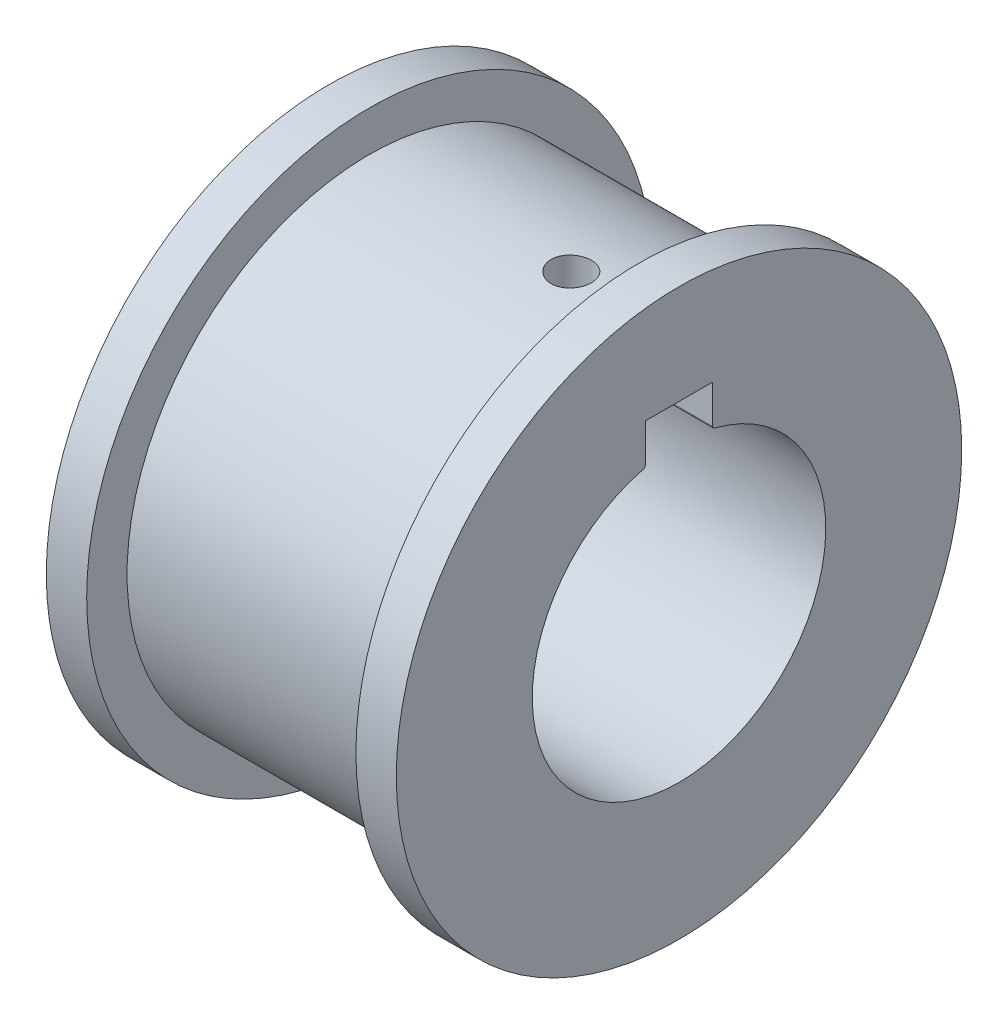
from build123d import *

# Parameters (mm, degrees)
SKETCH1_R               = 18
BOSS_EXTRUDE1_DEPTH     = 20
SKETCH3_R               = 21
BOSS_EXTRUDE2_DEPTH     = 3
SKETCH4_R               = 21
BOSS_EXTRUDE3_DEPTH     = 3
CUT_EXTRUDE2_DEPTH      = 3
CUT_EXTRUDE2_DEPTH_BACK = 25
SKETCH6_R               = 1.5
CUT_EXTRUDE3_DEPTH      = 20


with BuildPart() as part:
    # Sketch1 → Boss-Extrude1 (new body)
    with BuildSketch(Plane(origin=(0, 0, 0), x_dir=(0, 0, -1), z_dir=(1, 0, 0))):
        Circle(SKETCH1_R)
    extrude(amount=BOSS_EXTRUDE1_DEPTH)

    # Sketch3 → Boss-Extrude2 (add)
    with BuildSketch(Plane(origin=(20, 0, 0), x_dir=(0, 0, -1), z_dir=(1, 0, 0))):
        Circle(SKETCH3_R)
    extrude(amount=BOSS_EXTRUDE2_DEPTH)

    # Sketch4 → Boss-Extrude3 (add)
    with BuildSketch(Plane.ZY):
        Circle(SKETCH4_R)
    extrude(amount=BOSS_EXTRUDE3_DEPTH)

    # Sketch2 → Cut-Extrude2 (cut, two sides)
    with BuildSketch(Plane(origin=(20, 0, 0), x_dir=(0, 0, -1), z_dir=(1, 0, 0))) as cut_extrude2_sk:
        with BuildLine():
            Line((-2.5, 13.609429768), (2.5, 13.609429768))
            Line((2.5, 13.609429768), (2.5, 10.766615067))
            ThreePointArc((2.5, 10.766615067), (2.542314031, 10.64359013), (2.651351351, 10.572622003))
            ThreePointArc((2.651351351, 10.572622003), (0, -10.9), (-2.651351351, 10.572622003))
            ThreePointArc((-2.651351351, 10.572622003), (-2.542314031, 10.64359013), (-2.5, 10.766615067))
            Line((-2.5, 10.766615067), (-2.5, 13.609429768))
        make_face()
    extrude(amount=CUT_EXTRUDE2_DEPTH, mode=Mode.SUBTRACT)
    extrude(cut_extrude2_sk.sketch, amount=-CUT_EXTRUDE2_DEPTH_BACK, mode=Mode.SUBTRACT)

    # Sketch6 → Cut-Extrude3 (cut)
    with BuildSketch(Plane.XZ.offset(-13.609429768)):
        with Locations((15, 0)):
            Circle(SKETCH6_R)
    extrude(amount=-CUT_EXTRUDE3_DEPTH, mode=Mode.SUBTRACT)


solid = part.part
